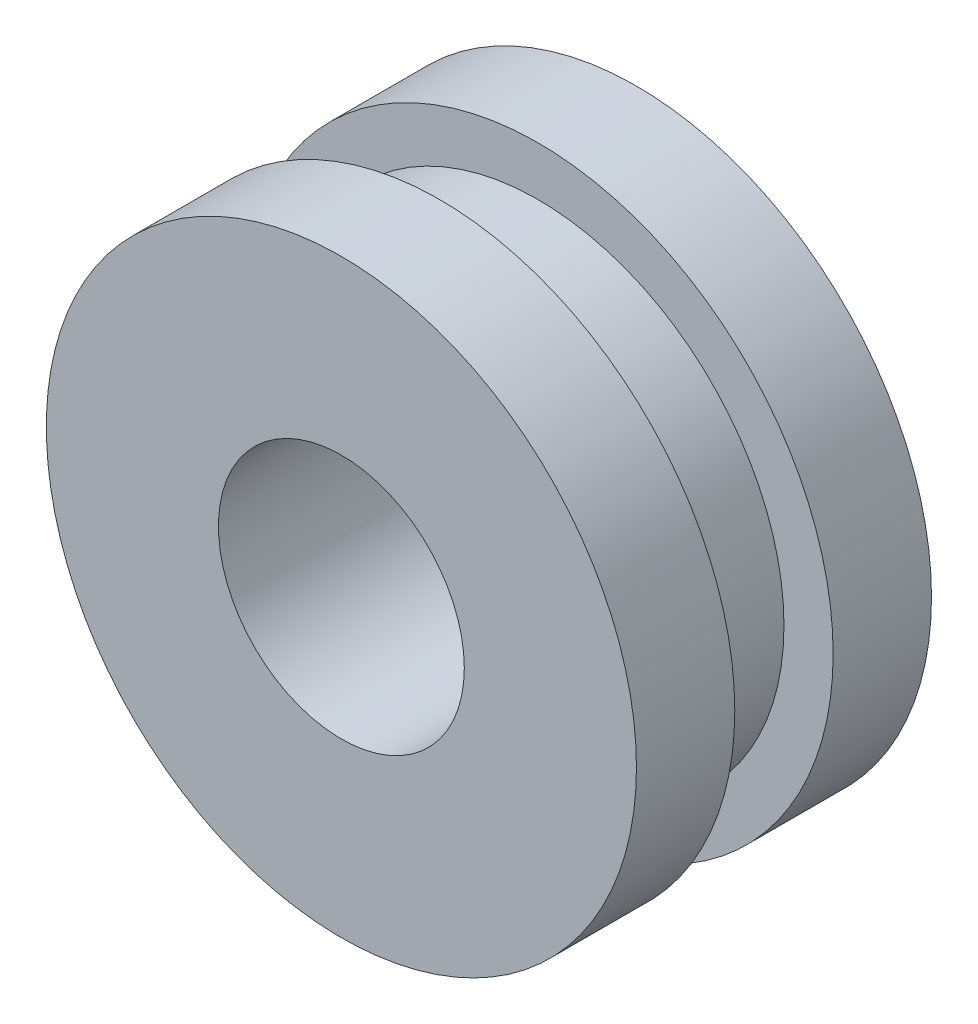
from build123d import *

# Parameters (mm, degrees)
SKETCH1_R           = 7.62
BOSS_EXTRUDE1_DEPTH = 2.54
SKETCH2_R           = 6.35
BOSS_EXTRUDE2_DEPTH = 2.54
SKETCH4_R           = 3.175
CUT_EXTRUDE1_DEPTH  = 8.62


with BuildPart() as part:
    # Sketch1 → Boss-Extrude1 (new body)
    with BuildSketch(Plane.XY):
        Circle(SKETCH1_R)
    boss_extrude1 = extrude(amount=BOSS_EXTRUDE1_DEPTH)

    # Sketch2 → Boss-Extrude2 (add)
    with BuildSketch(Plane.XY.offset(2.54)):
        Circle(SKETCH2_R)
    extrude(amount=BOSS_EXTRUDE2_DEPTH)

    # Mirror1: Boss-Extrude1 across plane
    add(boss_extrude1.mirror(Plane.XY.offset(3.81)))

    # Sketch4 → Cut-Extrude1 (cut, through all)
    with BuildSketch(Plane.XY.offset(7.62)):
        Circle(SKETCH4_R)
    extrude(amount=-CUT_EXTRUDE1_DEPTH, mode=Mode.SUBTRACT)


solid = part.part
